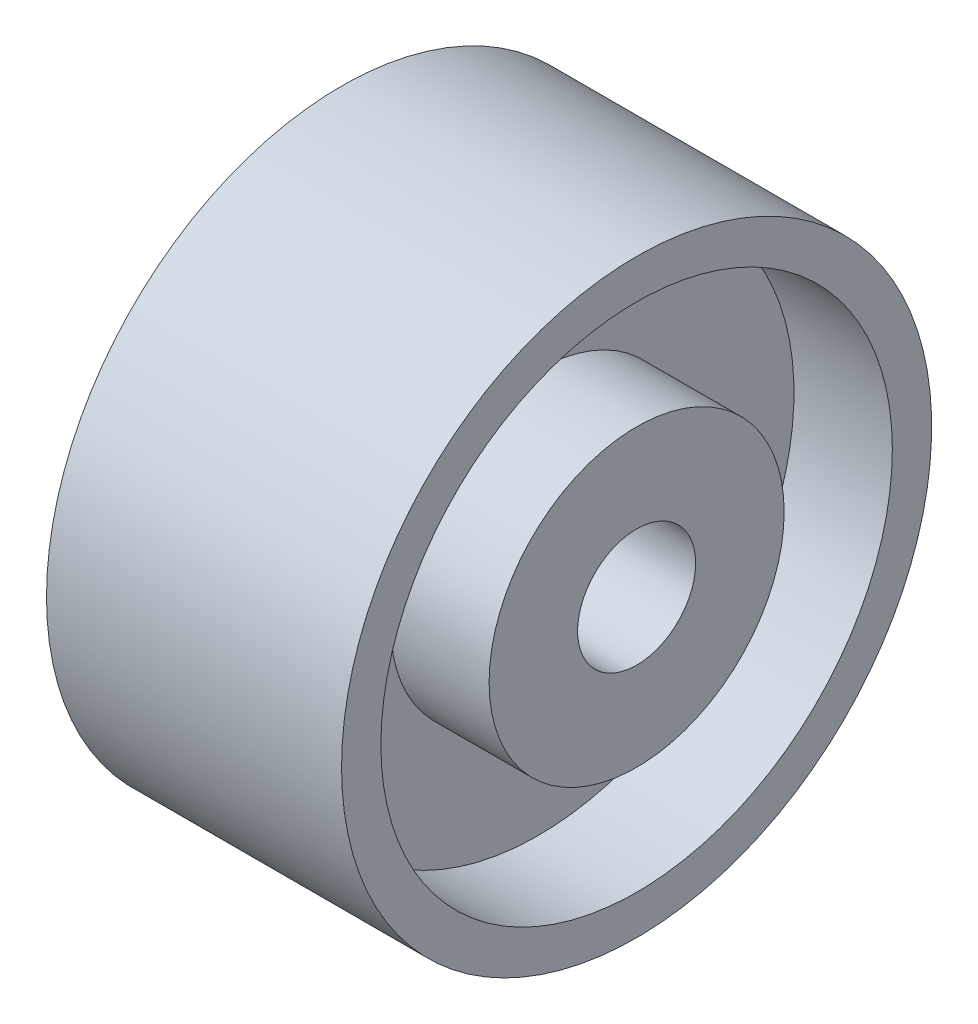
from build123d import *

# Parameters (mm, degrees)
IZIM1_R                          = 15
Y_KSEKLIK_EKSTR_ZYON1_DEPTH      = 30
IZIM2_R                          = 10
KES_EKSTR_ZYON2_DEPTH            = 30
IZIM13_R                         = 30
Y_KSEKLIK_EKSTR_ZYON3_DEPTH      = 30
IZIM14_R                         = 26
KES_EKSTR_ZYON3_DEPTH            = 15
IZIM15_R                         = 15
Y_KSEKLIK_EKSTR_ZYON4_DEPTH      = 15
Y_KSEKLIK_EKSTR_ZYON4_DEPTH_BACK = 15
IZIM16_R                         = 10
KES_EKSTR_ZYON5_DEPTH            = 45
IZIM17_R                         = 26
KES_EKSTR_ZYON8_DEPTH            = 1
KES_EKSTR_ZYON8_DEPTH_BACK       = 15
IZIM19_R                         = 26
Y_KSEKLIK_EKSTR_ZYON5_DEPTH      = 5
Y_KSEKLIK_EKSTR_ZYON5_DEPTH_BACK = 5
IZIM20_R                         = 15
Y_KSEKLIK_EKSTR_ZYON6_DEPTH      = 10
IZIM21_R                         = 10
KES_EKSTR_ZYON9_DEPTH            = 55
IZIM24_R                         = 15
KES_EKSTR_ZYON10_DEPTH           = 15
IZIM26_R                         = 10
IZIM26_R_2                       = 6
Y_KSEKLIK_EKSTR_ZYON7_DEPTH      = 30


with BuildPart() as part:
    # Çizim1 → Yükseklik-Ekstrüzyon1 (new body)
    with BuildSketch(Plane(origin=(0, 0, 0), x_dir=(0, 0, -1), z_dir=(1, 0, 0))):
        Circle(IZIM1_R)
    extrude(amount=Y_KSEKLIK_EKSTR_ZYON1_DEPTH)

    # Çizim2 → Kes-Ekstrüzyon2 (cut)
    with BuildSketch(Plane.ZY):
        Circle(IZIM2_R)
    extrude(amount=-KES_EKSTR_ZYON2_DEPTH, mode=Mode.SUBTRACT)

    # Çizim13 → Yükseklik-Ekstrüzyon3 (add)
    with BuildSketch(Plane.ZY):
        Circle(IZIM13_R)
    extrude(amount=-Y_KSEKLIK_EKSTR_ZYON3_DEPTH)

    # Çizim14 → Kes-Ekstrüzyon3 (cut)
    with BuildSketch(Plane.ZY):
        Circle(IZIM14_R)
    extrude(amount=-KES_EKSTR_ZYON3_DEPTH, mode=Mode.SUBTRACT)

    # Çizim15 → Yükseklik-Ekstrüzyon4 (add, two sides)
    with BuildSketch(Plane.ZY) as y_kseklik_ekstr_zyon4_sk:
        Circle(IZIM15_R)
    extrude(amount=Y_KSEKLIK_EKSTR_ZYON4_DEPTH)
    extrude(y_kseklik_ekstr_zyon4_sk.sketch, amount=-Y_KSEKLIK_EKSTR_ZYON4_DEPTH_BACK)

    # Çizim16 → Kes-Ekstrüzyon5 (cut)
    with BuildSketch(Plane.ZY.offset(15)):
        Circle(IZIM16_R)
    extrude(amount=-KES_EKSTR_ZYON5_DEPTH, mode=Mode.SUBTRACT)

    # Çizim17 → Kes-Ekstrüzyon8 (cut, two sides)
    with BuildSketch(Plane(origin=(30, 0, 0), x_dir=(0, 0, -1), z_dir=(1, 0, 0))) as kes_ekstr_zyon8_sk:
        Circle(IZIM17_R)
    extrude(amount=KES_EKSTR_ZYON8_DEPTH, mode=Mode.SUBTRACT)
    extrude(kes_ekstr_zyon8_sk.sketch, amount=-KES_EKSTR_ZYON8_DEPTH_BACK, mode=Mode.SUBTRACT)

    # Çizim19 → Yükseklik-Ekstrüzyon5 (add, two sides)
    with BuildSketch(Plane.ZY.offset(-15)) as y_kseklik_ekstr_zyon5_sk:
        Circle(IZIM19_R)
    extrude(amount=Y_KSEKLIK_EKSTR_ZYON5_DEPTH)
    extrude(y_kseklik_ekstr_zyon5_sk.sketch, amount=-Y_KSEKLIK_EKSTR_ZYON5_DEPTH_BACK)

    # Çizim20 → Yükseklik-Ekstrüzyon6 (add)
    with BuildSketch(Plane(origin=(20, 0, 0), x_dir=(0, 0, -1), z_dir=(1, 0, 0))):
        Circle(IZIM20_R)
    extrude(amount=Y_KSEKLIK_EKSTR_ZYON6_DEPTH)

    # Çizim21 → Kes-Ekstrüzyon9 (cut)
    with BuildSketch(Plane.ZY.offset(15)):
        Circle(IZIM21_R)
    extrude(amount=-KES_EKSTR_ZYON9_DEPTH, mode=Mode.SUBTRACT)

    # Çizim24 → Kes-Ekstrüzyon10 (cut)
    with BuildSketch(Plane.ZY.offset(15)):
        Circle(IZIM24_R)
    extrude(amount=-KES_EKSTR_ZYON10_DEPTH, mode=Mode.SUBTRACT)

    # Çizim26 → Yükseklik-Ekstrüzyon7 (add)
    with BuildSketch(Plane(origin=(0, 0, 0), x_dir=(0, 0, -1), z_dir=(1, 0, 0))):
        Circle(IZIM26_R)
        Circle(IZIM26_R_2, mode=Mode.SUBTRACT)
    extrude(amount=Y_KSEKLIK_EKSTR_ZYON7_DEPTH)


solid = part.part
